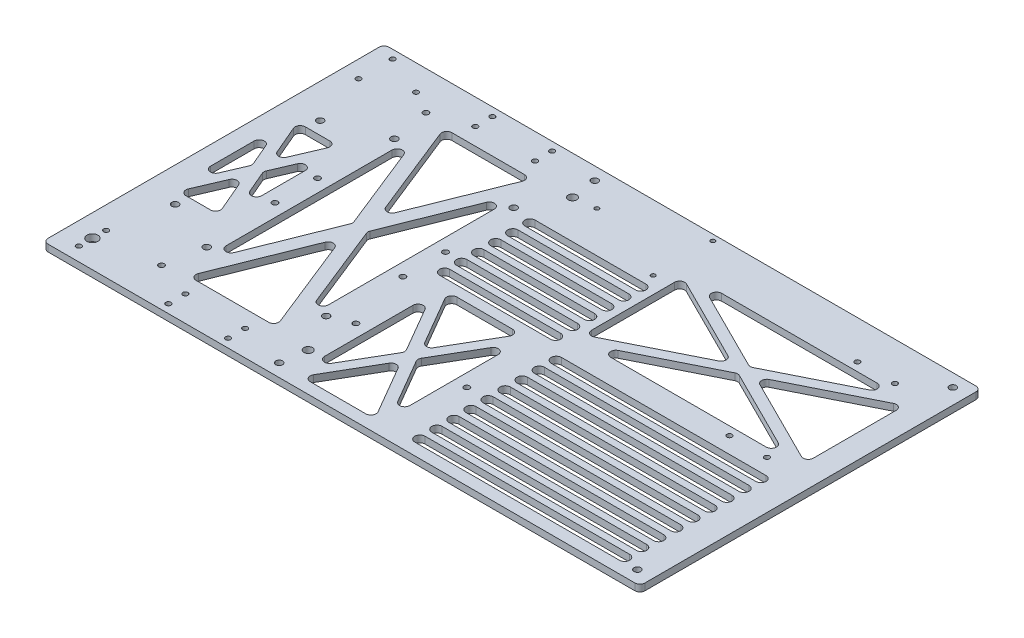
from build123d import *

# Parameters (mm, degrees)
SKETCH_1_W             = 228
SKETCH_1_H             = 200
EXTRUDE_1_DEPTH        = 4
SKETCH_7_W             = 200
SKETCH_7_H             = 4
EXTRUDE_2_DEPTH        = 122
SKETCH_10_R            = 2
CUT_EXTRUDE_5_DEPTH    = 5
SKETCH_17_R            = 2
CUT_EXTRUDE_9_DEPTH    = 5
SKETCH_18_R            = 1.5
CUT_EXTRUDE_11_DEPTH   = 5
SKETCH_19_R            = 1.5
SKETCH_19_R_2          = 3.2
CUT_EXTRUDE_12_DEPTH   = 5
SKETCH_23_R            = 2
CUT_EXTRUDE_15_DEPTH   = 5
SKETCH_30_R            = 1.5
CUT_EXTRUDE_18_DEPTH   = 5
HOLE_WIZARD_M4_3_D     = 3.3
HOLE_WIZARD_M4_3_DEPTH = 4
SKETCH_35_R            = 1.5
CUT_EXTRUDE_19_DEPTH   = 5
HOLE_WIZARD_M4_1_D     = 3.3
HOLE_WIZARD_M4_1_DEPTH = 4
CUT_EXTRUDE_22_DEPTH   = 10
HOLE_WIZARD_M4_2_D     = 3.3
HOLE_WIZARD_M4_2_DEPTH = 4
HOLE_WIZARD_M3_4_D     = 2.5
HOLE_WIZARD_M3_4_DEPTH = 4
SKETCH_58_R            = 2.5
CUT_EXTRUDE_30_DEPTH   = 5
CUT_EXTRUDE_31_DEPTH   = 5
PATTERN_LINEAR_1_COUNT = 9
PATTERN_LINEAR_1_PITCH = 10
CUT_EXTRUDE_32_DEPTH   = 10
CUT_EXTRUDE_33_DEPTH   = 10
CUT_EXTRUDE_34_DEPTH   = 5
PATTERN_LINEAR_2_COUNT = 6
PATTERN_LINEAR_2_PITCH = 10
CUT_EXTRUDE_35_DEPTH   = 10
FILLET_2_R             = 3
FILLET_3_R             = 3
FILLET_4_R             = 3
FILLET_5_R             = 3
FILLET_6_R             = 3


with BuildPart() as part:
    # 草图1 → 凸台-拉伸1 (new body)
    with BuildSketch(Plane(origin=(0, 0, 0), x_dir=(1, 0, 0), z_dir=(0, 1, 0))):
        Rectangle(SKETCH_1_W, SKETCH_1_H)
    extrude(amount=EXTRUDE_1_DEPTH)

    # 草图7 → 凸台-拉伸2 (add)
    with BuildSketch(Plane.ZY.offset(114)):
        with Locations((0, 2)):
            Rectangle(SKETCH_7_W, SKETCH_7_H)
    extrude(amount=EXTRUDE_2_DEPTH)

    # 草图10 → 切除-拉伸5 (cut, through all)
    with BuildSketch(Plane(origin=(0, 4, 0), x_dir=(1, 0, 0), z_dir=(0, 1, 0))):
        with Locations((-105, 92.5)):
            Circle(SKETCH_10_R)
        with Locations((-105, -92.5)):
            Circle(SKETCH_10_R)
        with Locations((105, -92.5)):
            Circle(SKETCH_10_R)
        with Locations((105, 92.5)):
            Circle(SKETCH_10_R)
    extrude(amount=-CUT_EXTRUDE_5_DEPTH, mode=Mode.SUBTRACT)

    # 草图17 → 切除-拉伸9 (cut, through all)
    with BuildSketch(Plane(origin=(0, 4, 0), x_dir=(1, 0, 0), z_dir=(0, 1, 0))):
        with Locations((-216, 42.5)):
            Circle(SKETCH_17_R)
        with Locations((-216, -42.5)):
            Circle(SKETCH_17_R)
    extrude(amount=-CUT_EXTRUDE_9_DEPTH, mode=Mode.SUBTRACT)

    # 草图18 → 切除-拉伸11 (cut, through all)
    with BuildSketch(Plane(origin=(0, 4, 0), x_dir=(1, 0, 0), z_dir=(0, 1, 0))):
        with Locations((-226, 95)):
            Circle(SKETCH_18_R)
        with Locations((-226, 75)):
            Circle(SKETCH_18_R)
        with Locations((-202.3, 85)):
            Circle(SKETCH_18_R)
    extrude(amount=-CUT_EXTRUDE_11_DEPTH, mode=Mode.SUBTRACT)

    # 草图19 → 切除-拉伸12 (cut, through all)
    with BuildSketch(Plane.XZ):
        with Locations((-223, 92)):
            Circle(SKETCH_19_R)
        with Locations((-223, 76)):
            Circle(SKETCH_19_R)
        with Locations((-223, 84)):
            Circle(SKETCH_19_R_2)
    extrude(amount=-CUT_EXTRUDE_12_DEPTH, mode=Mode.SUBTRACT)

    # 草图23 → 切除-拉伸15 (cut, through all)
    with BuildSketch(Plane.XZ):
        with Locations((-185, -55)):
            Circle(SKETCH_23_R)
        with Locations((-115, -55)):
            Circle(SKETCH_23_R)
        with Locations((-185, 55)):
            Circle(SKETCH_23_R)
        with Locations((-115, 55)):
            Circle(SKETCH_23_R)
    extrude(amount=-CUT_EXTRUDE_15_DEPTH, mode=Mode.SUBTRACT)

    # 草图30 → 切除-拉伸18 (cut, through all)
    with BuildSketch(Plane.XZ):
        with Locations((86, -77.5)):
            Circle(SKETCH_30_R)
        with Locations((64, -77.5)):
            Circle(SKETCH_30_R)
        with Locations((64, -2.5)):
            Circle(SKETCH_30_R)
        with Locations((86, -2.5)):
            Circle(SKETCH_30_R)
    extrude(amount=-CUT_EXTRUDE_18_DEPTH, mode=Mode.SUBTRACT)

    # M4 螺纹孔3
    with Locations(Plane(origin=(-189, 4, -77.5), x_dir=(0, 0, 1), z_dir=(0, 1, 0))):
        with Locations((0, 0)):
            hole_wizard_m4_3 = Hole(HOLE_WIZARD_M4_3_D / 2, depth=HOLE_WIZARD_M4_3_DEPTH)

    # 镜向1: M4 螺纹孔3 across plane
    add(hole_wizard_m4_3.mirror(Plane.XY), mode=Mode.SUBTRACT)

    # 草图35 → 切除-拉伸19 (cut, through all)
    with BuildSketch(Plane.XZ):
        with Locations((-167.5, 95)):
            Circle(SKETCH_35_R)
        with Locations((-132.5, 95)):
            Circle(SKETCH_35_R)
        with Locations((-167.5, -95)):
            Circle(SKETCH_35_R)
        with Locations((-132.5, -95)):
            Circle(SKETCH_35_R)
        with Locations((-132.5, 85)):
            Circle(SKETCH_35_R)
        with Locations((-167.5, 85)):
            Circle(SKETCH_35_R)
        with Locations((-132.5, -85)):
            Circle(SKETCH_35_R)
        with Locations((-167.5, -85)):
            Circle(SKETCH_35_R)
    extrude(amount=-CUT_EXTRUDE_19_DEPTH, mode=Mode.SUBTRACT)

    # M4 螺纹孔1
    with Locations(Plane(origin=(-112.5, 0, -12.5), x_dir=(0, 0, -1), z_dir=(0, -1, 0))):
        with Locations((0, 0), (-25, 0), (-25, -75), (0, -75)):
            Hole(HOLE_WIZARD_M4_1_D / 2, depth=HOLE_WIZARD_M4_1_DEPTH)

    # 草图43 → 切除-拉伸22 (cut)
    with BuildSketch(Plane(origin=(0, 0, 0), x_dir=(-1, 0, 0), z_dir=(0, -1, 0))):
        Polygon((175.691868154, -75), (150, -10.770329614), (124.308131846, -75), align=None)
        Polygon((120, -64.229670386), (145.691868154, 0), (120, 64.229670386), align=None)
        Polygon((124.308131846, 75), (150, 10.770329614), (175.691868154, 75), align=None)
        Polygon((154.308131846, 0), (180, -64.229670386), (180, 64.229670386), align=None)
    extrude(amount=-CUT_EXTRUDE_22_DEPTH, mode=Mode.SUBTRACT)

    # M4 螺纹孔2
    with Locations(Plane(origin=(-37.5, 0, 50), x_dir=(0, 0, -1), z_dir=(0, -1, 0))):
        with Locations((0, 0), (0, -65)):
            Hole(HOLE_WIZARD_M4_2_D / 2, depth=HOLE_WIZARD_M4_2_DEPTH)

    # M3 螺纹孔4
    with Locations(Plane(origin=(-90.25, 0, -79), x_dir=(0, 0, -1), z_dir=(0, -1, 0))):
        with Locations((0, 0), (-17.5, 50.5), (17.5, 50.5)):
            Hole(HOLE_WIZARD_M3_4_D / 2, depth=HOLE_WIZARD_M3_4_DEPTH)

    # 草图58 → 切除-拉伸30 (cut, through all)
    with BuildSketch(Plane(origin=(0, 0, 0), x_dir=(-1, 0, 0), z_dir=(0, -1, 0))):
        with Locations((103, -77.5)):
            Circle(SKETCH_58_R)
    cut_extrude_30 = extrude(amount=-CUT_EXTRUDE_30_DEPTH, mode=Mode.SUBTRACT)

    # 镜向3: 切除-拉伸30 across plane
    add(cut_extrude_30.mirror(Plane.XY), mode=Mode.SUBTRACT)

    # 草图59 → 切除-拉伸31 (cut, through all)
    with BuildSketch(Plane.XZ):
        with BuildLine():
            Line((-25, 93), (95, 93))
            ThreePointArc((95, 93), (98, 90), (95, 87))
            Line((95, 87), (-25, 87))
            ThreePointArc((-25, 87), (-28, 90), (-25, 93))
        make_face()
    cut_extrude_31 = extrude(amount=-CUT_EXTRUDE_31_DEPTH, mode=Mode.SUBTRACT)

    # 阵列(线性)1: 切除-拉伸31 ×9
    with Locations(*[(0, 0, -i * PATTERN_LINEAR_1_PITCH) for i in range(1, PATTERN_LINEAR_1_COUNT)]):
        add(cut_extrude_31, mode=Mode.SUBTRACT)

    # 草图60 → 切除-拉伸32 (cut)
    with BuildSketch(Plane(origin=(0, 0, 0), x_dir=(-1, 0, 0), z_dir=(0, -1, 0))):
        Polygon((23.291796068, 7.5), (-35, 36.645898034), (-93.291796068, 7.5), align=None)
        Polygon((-28.291796068, 40), (30, 10.854101966), (30, 69.145898034), align=None)
        Polygon((-93.291796068, 72.5), (-35, 43.354101966), (23.291796068, 72.5), align=None)
        Polygon((-100, 10.854101966), (-41.708203932, 40), (-100, 69.145898034), align=None)
    extrude(amount=-CUT_EXTRUDE_32_DEPTH, mode=Mode.SUBTRACT)

    # 草图62 → 切除-拉伸33 (cut)
    with BuildSketch(Plane(origin=(0, 0, 0), x_dir=(-1, 0, 0), z_dir=(0, -1, 0))):
        Polygon((48.470185148, -93), (91.529814852, -93), (70, -55.968718455), align=None)
        Polygon((73.470185148, -50), (95, -87.031281545), (95, -12.968718455), align=None)
        Polygon((45, -87.031281545), (66.529814852, -50), (45, -12.968718455), align=None)
        Polygon((48.470185148, -7), (70, -44.031281545), (91.529814852, -7), align=None)
    extrude(amount=-CUT_EXTRUDE_33_DEPTH, mode=Mode.SUBTRACT)

    # 草图63 → 切除-拉伸34 (cut, through all)
    with BuildSketch(Plane(origin=(0, 0, 0), x_dir=(-1, 0, 0), z_dir=(0, -1, 0))):
        with BuildLine():
            Line((102.5, -1), (37.5, -1))
            ThreePointArc((37.5, -1), (34.5, 2), (37.5, 5))
            Line((37.5, 5), (102.5, 5))
            ThreePointArc((102.5, 5), (105.5, 2), (102.5, -1))
        make_face()
    cut_extrude_34 = extrude(amount=-CUT_EXTRUDE_34_DEPTH, mode=Mode.SUBTRACT)

    # 阵列(线性)2: 切除-拉伸34 ×6
    with Locations(*[(0, 0, -i * PATTERN_LINEAR_2_PITCH) for i in range(1, PATTERN_LINEAR_2_COUNT)]):
        add(cut_extrude_34, mode=Mode.SUBTRACT)

    # 草图65 → 切除-拉伸35 (cut)
    with BuildSketch(Plane(origin=(0, 0, 0), x_dir=(-1, 0, 0), z_dir=(0, -1, 0))):
        Polygon((221.73609724, -35), (210, -7.615773106), (198.26390276, -35), align=None)
        Polygon((195, -27.384226894), (206.73609724, 0), (195, 27.384226894), align=None)
        Polygon((198.26390276, 35), (210, 7.615773106), (221.73609724, 35), align=None)
        Polygon((213.26390276, 0), (225, -27.384226894), (225, 27.384226894), align=None)
    extrude(amount=-CUT_EXTRUDE_35_DEPTH, mode=Mode.SUBTRACT)

    # 圆角2
    fillet_2_edges = [part.edges().sort_by_distance(p)[0] for p in [
        (-236, 2, -100),
        (-236, 2, 100),
        (114, 2, 100),
        (114, 2, -100),
    ]]
    fillet(fillet_2_edges, radius=FILLET_2_R)

    # 圆角3
    fillet_3_edges = [part.edges().sort_by_distance(p)[0] for p in [
        (-221.73609724, 2, -35),
        (-210, 2, -7.615773106),
        (-198.26390276, 2, -35),
        (-206.73609724, 2, 0),
        (-195, 2, 27.384226894),
        (-195, 2, -27.384226894),
        (-225, 2, -27.384226894),
        (-225, 2, 27.384226894),
        (-213.26390276, 2, 0),
        (-210, 2, 7.615773106),
        (-221.73609724, 2, 35),
        (-198.26390276, 2, 35),
    ]]
    fillet(fillet_3_edges, radius=FILLET_3_R)

    # 圆角4
    fillet_4_edges = [part.edges().sort_by_distance(p)[0] for p in [
        (-175.691868154, 2, -75),
        (-150, 2, -10.770329614),
        (-124.308131846, 2, -75),
        (-145.691868154, 2, 0),
        (-120, 2, 64.229670386),
        (-120, 2, -64.229670386),
        (-180, 2, -64.229670386),
        (-180, 2, 64.229670386),
        (-154.308131846, 2, 0),
        (-150, 2, 10.770329614),
        (-175.691868154, 2, 75),
        (-124.308131846, 2, 75),
    ]]
    fillet(fillet_4_edges, radius=FILLET_4_R)

    # 圆角5
    fillet_5_edges = [part.edges().sort_by_distance(p)[0] for p in [
        (-95, 2, 12.968718455),
        (-95, 2, 87.031281545),
        (-73.470185148, 2, 50),
        (-66.529814852, 2, 50),
        (-45, 2, 87.031281545),
        (-45, 2, 12.968718455),
        (-91.529814852, 2, 7),
        (-70, 2, 44.031281545),
        (-48.470185148, 2, 7),
        (-70, 2, 55.968718455),
        (-91.529814852, 2, 93),
        (-48.470185148, 2, 93),
    ]]
    fillet(fillet_5_edges, radius=FILLET_5_R)

    # 圆角6
    fillet_6_edges = [part.edges().sort_by_distance(p)[0] for p in [
        (-23.291796068, 2, -72.5),
        (35, 2, -43.354101966),
        (93.291796068, 2, -72.5),
        (-30, 2, -69.145898034),
        (-30, 2, -10.854101966),
        (28.291796068, 2, -40),
        (41.708203932, 2, -40),
        (100, 2, -10.854101966),
        (100, 2, -69.145898034),
        (35, 2, -36.645898034),
        (-23.291796068, 2, -7.5),
        (93.291796068, 2, -7.5),
    ]]
    fillet(fillet_6_edges, radius=FILLET_6_R)


solid = part.part
